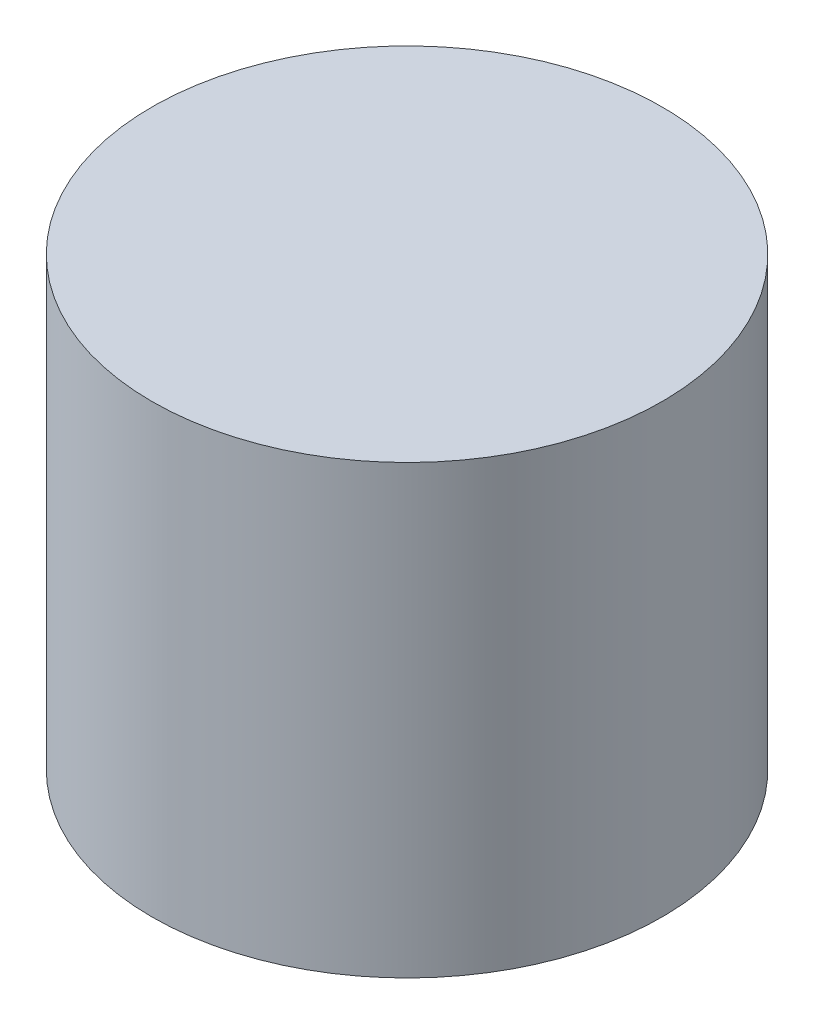
from build123d import *

# Parameters (mm, degrees)
SKETCH_1_R      = 4
EXTRUDE_2_DEPTH = 7


with BuildPart() as part:
    # Эскиз1 → Бобышка-Вытянуть2 (new body)
    with BuildSketch(Plane(origin=(0, 0, 0), x_dir=(1, 0, 0), z_dir=(0, 1, 0))):
        with Locations((-1.102254688, 0.343154761)):
            Circle(SKETCH_1_R)
    extrude(amount=EXTRUDE_2_DEPTH)


solid = part.part
